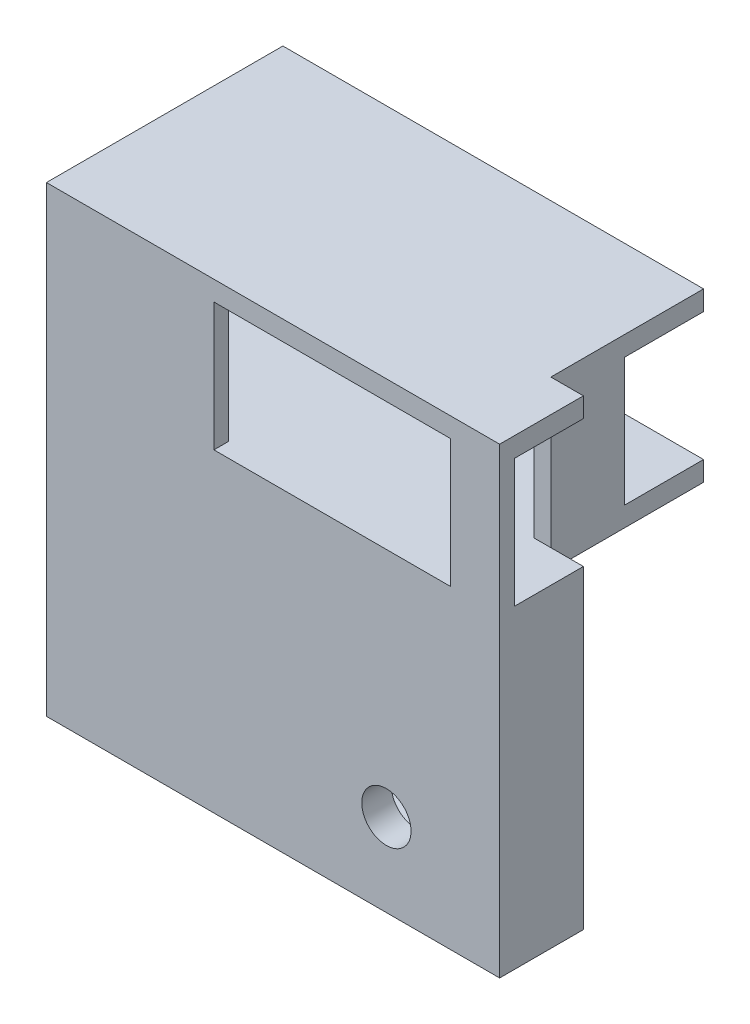
from build123d import *

# Parameters (mm, degrees)
SKETCH_1_W          = 34
SKETCH_1_H          = 17
SKETCH_1_W_2        = 24
SKETCH_1_H_2        = 13
EXTRUDE_1_DEPTH     = 1.5
SKETCH_4_R          = 1
EXTRUDE_4_DEPTH     = 1
EXTRUDE_4_TAPER     = 43
SKETCH_3_W          = 34
SKETCH_3_H          = 2
EXTRUDE_5_DEPTH     = 7
SKETCH_5_W          = 1.698300115
SKETCH_5_H          = 2
SKETCH_5_W_2        = 29
EXTRUDE_6_DEPTH     = 15.5
CUT_EXTRUDE_1_REACH = 7
SKETCH_6_W          = 8
SKETCH_6_H          = 13
EXTRUDE_7_DEPTH     = 12
SKETCH_10_W         = 24
SKETCH_10_H         = 29.92364145
SKETCH_10_W_2       = 22.5
SKETCH_10_H_2       = 13
EXTRUDE_8_DEPTH     = 3
SKETCH_11_W         = 46
SKETCH_11_H         = 29.92364145
EXTRUDE_9_DEPTH     = 3
SKETCH_12_W         = 16.749756905
SKETCH_12_H         = 24.683929902
SKETCH_12_W_2       = 2.349687525
SKETCH_12_H_2       = 24.562319206
EXTRUDE_10_DEPTH    = 5.5
EXTRUDE_START       = -3.202635
EXTRUDE_11_DEPTH    = 3.202635
CUT_EXTRUDE_2_REACH = 26
SKETCH_14_R         = 2.5


with BuildPart() as part:
    # 草图1 → 凸台-拉伸1 (new body)
    with BuildSketch(Plane.XY):
        with Locations((-12, 6.5)):
            Rectangle(SKETCH_1_W, SKETCH_1_H)
        with Locations((-12, 6.5)):
            Rectangle(SKETCH_1_W_2, SKETCH_1_H_2, mode=Mode.SUBTRACT)
    extrude(amount=EXTRUDE_1_DEPTH)

    # 草图4 → 凸台-拉伸4 (add)
    with BuildSketch(Plane.XY):
        with Locations((2.6, 10)):
            Circle(SKETCH_4_R)
        with Locations((2.6, 3)):
            Circle(SKETCH_4_R)
        with Locations((-26.6, 10)):
            Circle(SKETCH_4_R)
        with Locations((-26.6, 3)):
            Circle(SKETCH_4_R)
    extrude(amount=-EXTRUDE_4_DEPTH, taper=EXTRUDE_4_TAPER)

    # 草图3 → 凸台-拉伸5 (add)
    with BuildSketch(Plane(origin=(0, 0, 0), x_dir=(-1, 0, 0), z_dir=(0, 0, -1))):
        with Locations((12, -1)):
            Rectangle(SKETCH_3_W, SKETCH_3_H)
        with Locations((12, 14)):
            Rectangle(SKETCH_3_W, SKETCH_3_H)
    extrude(amount=EXTRUDE_5_DEPTH)

    # 草图5 → 凸台-拉伸6 (add)
    with BuildSketch(Plane(origin=(0, 0, -7), x_dir=(-1, 0, 0), z_dir=(0, 0, -1))):
        with Locations((-0.849150058, -1)):
            Rectangle(SKETCH_5_W, SKETCH_5_H)
        with Locations((14.5, -1)):
            Rectangle(SKETCH_5_W_2, SKETCH_5_H)
        Polygon((0, 15), (-1.698300115, 15), (-1.698300115, 0), (0, 0), (0, 13), align=None)
        with Locations((14.5, 14)):
            Rectangle(SKETCH_5_W_2, SKETCH_5_H)
    extrude(amount=EXTRUDE_6_DEPTH)

    # 草图6 → 切除-拉伸1 (cut, up to next)
    with BuildSketch(Plane.ZY, mode=Mode.PRIVATE) as cut_extrude_1_sk1:
        with Locations((-18.5, 6.5)):
            Rectangle(SKETCH_6_W, SKETCH_6_H)
    cut_extrude_1_tool1 = extrude(cut_extrude_1_sk1.sketch, amount=-CUT_EXTRUDE_1_REACH, mode=Mode.PRIVATE) & part.part
    add(cut_extrude_1_tool1.solids().sort_by_distance((0, 6.5, -18.5))[0], mode=Mode.SUBTRACT)

    # 草图9 → 凸台-拉伸7 (add)
    with BuildSketch(Plane.ZY.offset(29)):
        Polygon((-22.5, 15), (1.5, 15), (1.5, -2), (-22.5, -2), (-22.5, 0), (0, 0), (0, 13), (-22.5, 13), align=None)
    extrude(amount=EXTRUDE_7_DEPTH)

    # 草图10 → 凸台-拉伸8 (add)
    with BuildSketch(Plane.ZY.offset(41)):
        with Locations((-10.5, -16.961820725)):
            Rectangle(SKETCH_10_W, SKETCH_10_H)
        with Locations((-11.25, 6.5)):
            Rectangle(SKETCH_10_W_2, SKETCH_10_H_2)
        Polygon((1.5, 15), (-22.5, 15), (-22.5, 13), (0, 13), (0, 0), (-22.5, 0), (-22.5, -2), (1.5, -2), align=None)
    extrude(amount=-EXTRUDE_8_DEPTH)

    # 草图11 → 凸台-拉伸9 (add)
    with BuildSketch(Plane.XY.offset(1.5)):
        with Locations((-18, -16.961820725)):
            Rectangle(SKETCH_11_W, SKETCH_11_H)
    extrude(amount=-EXTRUDE_9_DEPTH)

    # 草图12 → 凸台-拉伸10 (add)
    with BuildSketch(Plane(origin=(0, 0, -1.5), x_dir=(-1, 0, 0), z_dir=(0, 0, -1))):
        Polygon((-5, -2), (-5, -31.92364145), (16.5, -31.92364145), (16.5, -28.721006537), (16.5, -4.158687331), (16.5, -2), align=None)
        with Locations((5.65486472, -16.500652282)):
            Rectangle(SKETCH_12_W, SKETCH_12_H, mode=Mode.SUBTRACT)
        Polygon((16.5, -28.721006537), (16.5, -31.92364145), (38, -31.92364145), (38, -28.721006537), (35.650312475, -28.721006537), align=None)
        with Locations((36.825156237, -16.439846934)):
            Rectangle(SKETCH_12_W_2, SKETCH_12_H_2)
        Polygon((38, -2), (16.5, -2), (16.5, -4.158687331), (35.650312475, -4.158687331), (38, -4.158687331), align=None)
    extrude(amount=EXTRUDE_10_DEPTH)

    # 草图13 → 凸台-拉伸11 (add)
    with BuildSketch(Plane.XZ.offset(31.92364145).offset(EXTRUDE_START)):
        Polygon((-38, -22.5), (-22.5, -7), (-38, -7), align=None)
    extrude(amount=EXTRUDE_11_DEPTH)

    # 草图14 → 切除-拉伸2 (cut, up to next)
    with BuildSketch(Plane.XY.offset(1.5), mode=Mode.PRIVATE) as cut_extrude_2_sk1:
        with Locations((-6.493645673, -23.522660126)):
            Circle(SKETCH_14_R)
    cut_extrude_2_tool1 = extrude(cut_extrude_2_sk1.sketch, amount=-CUT_EXTRUDE_2_REACH, mode=Mode.PRIVATE) & part.part
    add(cut_extrude_2_tool1.solids().sort_by_distance((-6.493646, -23.52266, 1.5))[0], mode=Mode.SUBTRACT)


solid = part.part
